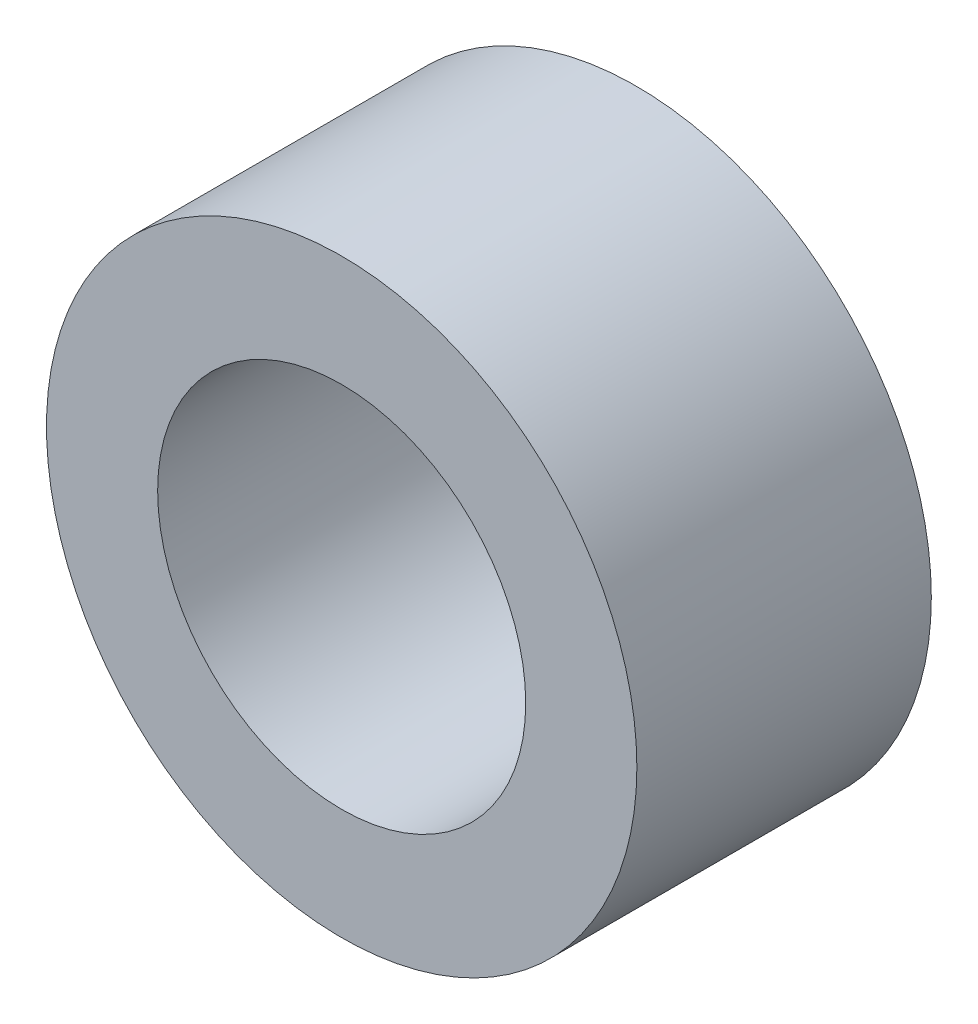
from build123d import *

# Parameters (mm, degrees)
SKETCH1_R      = 4.01
SKETCH1_R_2    = 2.5
EXTRUDE1_DEPTH = 2


with BuildPart() as part:
    # Sketch1 → Extrude1 (new body, symmetric)
    with BuildSketch(Plane.XY):
        Circle(SKETCH1_R)
        Circle(SKETCH1_R_2, mode=Mode.SUBTRACT)
    extrude(amount=EXTRUDE1_DEPTH, both=True)


solid = part.part
